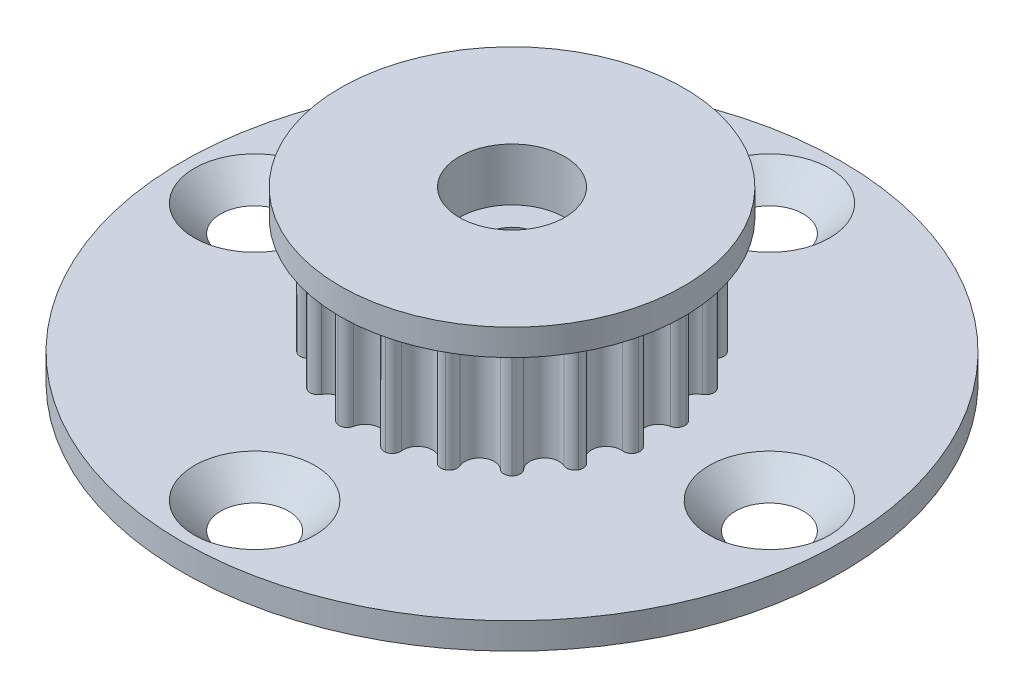
from build123d import *

# Parameters (mm, degrees)
BOSS_EXTRUDE1_DEPTH     = 3.556
CIRPATTERN1_COUNT       = 20
SKETCH2_W               = 10.342329408
SKETCH2_H               = 1.5875
SKETCH9_R               = 19.84375
SKETCH9_R_2             = 1.5
BOSS_EXTRUDE2_DEPTH     = 1.5875
SKETCH3_R               = 1.74625
CUT_EXTRUDE1_DEPTH      = 6.087499985
CUT_EXTRUDE1_DEPTH_BACK = 6.087499985
CIRPATTERN2_COUNT       = 4
SKETCH12_R              = 3.175
CUT_EXTRUDE2_DEPTH      = 3.175
SKETCH13_R              = 1.525
CUT_EXTRUDE4_DEPTH      = 7.99999997


with BuildPart() as part:
    # Sketch1 → Boss-Extrude1 (new body, symmetric)
    with BuildSketch(Plane(origin=(0, 0, 0), x_dir=(1, 0, 0), z_dir=(0, 1, 0))):
        with BuildLine():
            ThreePointArc((0.872060607, 8.659786465), (0.562967303, 8.148255135), (0, 7.947579308))
            ThreePointArc((0, 7.947579308), (-1.243275317, -7.849731418), (2.45593707, 7.55859709))
            ThreePointArc((2.45593707, 7.55859709), (1.982535589, 7.923417607), (1.846642263, 8.505427895))
            ThreePointArc((1.846642263, 8.505427895), (1.749626992, 8.862101959), (1.434119122, 9.054671776))
            ThreePointArc((1.434119122, 9.054671776), (1.074545959, 8.969024291), (0.872060607, 8.659786465))
        make_face()
    boss_extrude1 = extrude(amount=BOSS_EXTRUDE1_DEPTH, both=True)

    # CirPattern1: Boss-Extrude1 ×20 about axis
    cirpattern1_axis = Axis((0, 0, 0), (0, 1, 0))
    for i in range(1, CIRPATTERN1_COUNT):
        add(boss_extrude1.rotate(cirpattern1_axis, i * 360 / CIRPATTERN1_COUNT))

    # Sketch2 → Revolve3 (revolve)
    with BuildSketch(Plane(origin=(0, 0, 0), x_dir=(0, 0, -1), z_dir=(1, 0, 0))):
        with Locations((5.171164704, 4.293749985)):
            Rectangle(SKETCH2_W, SKETCH2_H)
    revolve3 = revolve(axis=Axis((0, 3.3, 0), (0, -1, 0)))

    # Mirror1: Revolve3 across plane
    add(revolve3.mirror(Plane.ZX))

    # Sketch9 → Boss-Extrude2 (add)
    with BuildSketch(Plane.XZ.offset(5.087499985)):
        Circle(SKETCH9_R)
        Circle(SKETCH9_R_2, mode=Mode.SUBTRACT)
    extrude(amount=-BOSS_EXTRUDE2_DEPTH)

    # Sketch3 → Cut-Extrude1 (cut, two sides)
    with BuildSketch(Plane(origin=(0, 0, 0), x_dir=(1, 0, 0), z_dir=(0, 1, 0))) as cut_extrude1_sk:
        with Locations((-15.5, 0)):
            Circle(SKETCH3_R)
        with Locations((0, 15.5)):
            Circle(SKETCH3_R)
        with Locations((15.5, 0)):
            Circle(SKETCH3_R)
        with Locations((0, -15.5)):
            Circle(SKETCH3_R)
    extrude(amount=CUT_EXTRUDE1_DEPTH, mode=Mode.SUBTRACT)
    extrude(cut_extrude1_sk.sketch, amount=-CUT_EXTRUDE1_DEPTH_BACK, mode=Mode.SUBTRACT)

    # Sketch6 → Cut-Revolve2 (revolve, cut)
    with BuildSketch(Plane.XY):
        Polygon((-11.8678, -3.499999985), (-15.5, -7.132199985), (-15.5, -3.499999985), align=None)
    cut_revolve2 = revolve(axis=Axis((-15.5, -5.087499985, 0), (0, 1, 0)), mode=Mode.SUBTRACT)

    # CirPattern2: Cut-Revolve2 ×4 about axis
    cirpattern2_axis = Axis((0, 0, 0), (0, 1, 0))
    for i in range(1, CIRPATTERN2_COUNT):
        add(cut_revolve2.rotate(cirpattern2_axis, i * 360 / CIRPATTERN2_COUNT), mode=Mode.SUBTRACT)

    # Sketch12 → Cut-Extrude2 (cut)
    with BuildSketch(Plane(origin=(0, 5.087499985, 0), x_dir=(1, 0, 0), z_dir=(0, 1, 0))):
        Circle(SKETCH12_R)
    extrude(amount=-CUT_EXTRUDE2_DEPTH, mode=Mode.SUBTRACT)

    # Sketch13 → Cut-Extrude4 (cut, through all)
    with BuildSketch(Plane(origin=(0, 1.912499985, 0), x_dir=(1, 0, 0), z_dir=(0, 1, 0))):
        Circle(SKETCH13_R)
    extrude(amount=-CUT_EXTRUDE4_DEPTH, mode=Mode.SUBTRACT)


solid = part.part
